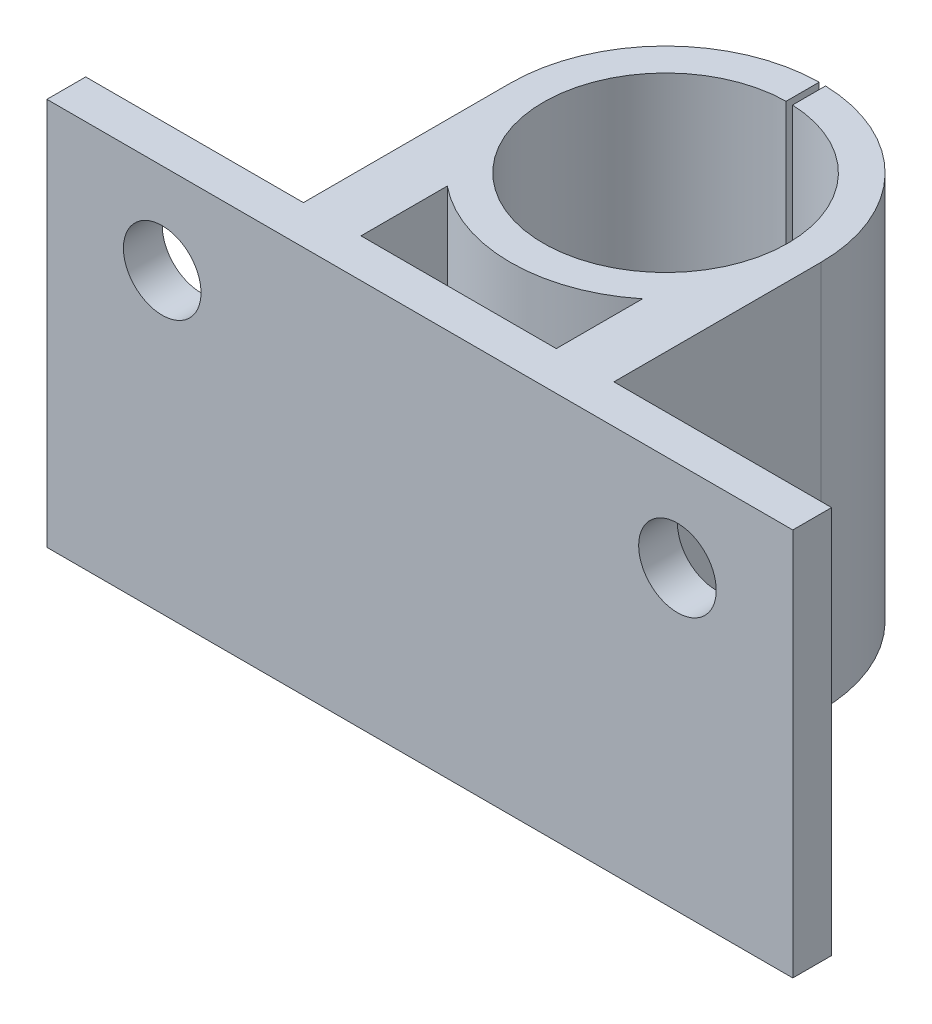
from build123d import *

# Parameters (mm, degrees)
SKETCH1_W           = 57.667844522
SKETCH1_H           = 30
BOSS_EXTRUDE1_DEPTH = 30
SKETCH2_R           = 4
CUT_EXTRUDE2_DEPTH  = 40
SKETCH4_R           = 8
SKETCH4_R_2         = 4
CUT_EXTRUDE3_DEPTH  = 31
SKETCH5_R           = 3
CUT_EXTRUDE4_DEPTH  = 4
SKETCH6_R           = 9.45
CUT_EXTRUDE6_DEPTH  = 31
BOSS_EXTRUDE2_DEPTH = 30
SKETCH8_W           = 0.5
SKETCH8_H           = 6.199937256
CUT_EXTRUDE7_DEPTH  = 31


with BuildPart() as part:
    # Sketch1 → Boss-Extrude1 (new body)
    with BuildSketch(Plane(origin=(0, 0, 0), x_dir=(1, 0, 0), z_dir=(0, 1, 0))):
        Rectangle(SKETCH1_W, SKETCH1_H)
    extrude(amount=BOSS_EXTRUDE1_DEPTH)

    # Sketch2 → Cut-Extrude2 (cut)
    with BuildSketch(Plane(origin=(0, 30, 0), x_dir=(1, 0, 0), z_dir=(0, 1, 0))):
        with Locations((0, 4)):
            Circle(SKETCH2_R)
    extrude(amount=-CUT_EXTRUDE2_DEPTH, mode=Mode.SUBTRACT)

    # Sketch4 → Cut-Extrude3 (cut, through all)
    with BuildSketch(Plane(origin=(0, 30, 0), x_dir=(1, 0, 0), z_dir=(0, 1, 0))):
        with Locations((0, 4)):
            Circle(SKETCH4_R)
        with Locations((0, 4)):
            Circle(SKETCH4_R_2, mode=Mode.SUBTRACT)
        with BuildLine():
            ThreePointArc((-11, 4), (-7.778174609, 11.778174577), (-4.5e-08, 15))
            Line((-4.5e-08, 15), (-28.833922261, 15))
            Line((-28.833922261, 15), (-28.833922261, -12))
            Line((-28.833922261, -12), (-11, -12))
            Line((-11, -12), (-11, 4))
        make_face()
        with BuildLine():
            ThreePointArc((-4.5e-08, 15), (7.778174577, 11.778174609), (11, 4))
            Line((11, 4), (11, -12))
            Line((11, -12), (28.833922261, -12))
            Line((28.833922261, -12), (28.833922261, 15))
            Line((28.833922261, 15), (-4.5e-08, 15))
        make_face()
        with BuildLine():
            Line((7.549834435, -12), (7.549834435, -4))
            ThreePointArc((7.549834435, -4), (0, -7), (-7.549834435, -4))
            Line((-7.549834435, -4), (-7.549834435, -12))
            Line((-7.549834435, -12), (7.549834435, -12))
        make_face()
    extrude(amount=-CUT_EXTRUDE3_DEPTH, mode=Mode.SUBTRACT)

    # Sketch5 → Cut-Extrude4 (cut, through all)
    with BuildSketch(Plane(origin=(0, 0, 12), x_dir=(-1, 0, 0), z_dir=(0, 0, -1))):
        with Locations((-19.916961131, 23)):
            Circle(SKETCH5_R)
        with Locations((19.916961131, 23)):
            Circle(SKETCH5_R)
    extrude(amount=-CUT_EXTRUDE4_DEPTH, mode=Mode.SUBTRACT)

    # Sketch6 → Cut-Extrude6 (cut, through all)
    with BuildSketch(Plane(origin=(0, 30, 0), x_dir=(1, 0, 0), z_dir=(0, 1, 0))):
        with Locations((0, 4)):
            Circle(SKETCH6_R)
    extrude(amount=-CUT_EXTRUDE6_DEPTH, mode=Mode.SUBTRACT)

    # Sketch7 → Boss-Extrude2 (add, through all)
    with BuildSketch(Plane(origin=(0, 30, 0), x_dir=(1, 0, 0), z_dir=(0, 1, 0))):
        with BuildLine():
            Line((11, 4), (11, -12))
            Line((11, -12), (12.001946675, -12))
            Line((12.001946675, -12), (12.001946675, 4))
            ThreePointArc((12.001946675, 4), (0, 16.001946675), (-12.001946675, 4))
            Line((-12.001946675, 4), (-12.001946675, -12))
            Line((-12.001946675, -12), (-11, -12))
            Line((-11, -12), (-11, 4))
            ThreePointArc((-11, 4), (0, 15), (11, 4))
        make_face()
        with BuildLine():
            ThreePointArc((-7.549834435, -5.329883385), (0, -8.001946675), (7.549834435, -5.329883385))
            Line((7.549834435, -5.329883385), (7.549834435, -4))
            ThreePointArc((7.549834435, -4), (0, -7), (-7.549834435, -4))
            Line((-7.549834435, -4), (-7.549834435, -5.329883385))
        make_face()
    extrude(amount=-BOSS_EXTRUDE2_DEPTH)

    # Sketch8 → Cut-Extrude7 (cut, through all)
    with BuildSketch(Plane(origin=(0, 30, 0), x_dir=(1, 0, 0), z_dir=(0, 1, 0))):
        with Locations((0.121996235, 15.101825576)):
            Rectangle(SKETCH8_W, SKETCH8_H)
    extrude(amount=-CUT_EXTRUDE7_DEPTH, mode=Mode.SUBTRACT)


solid = part.part
